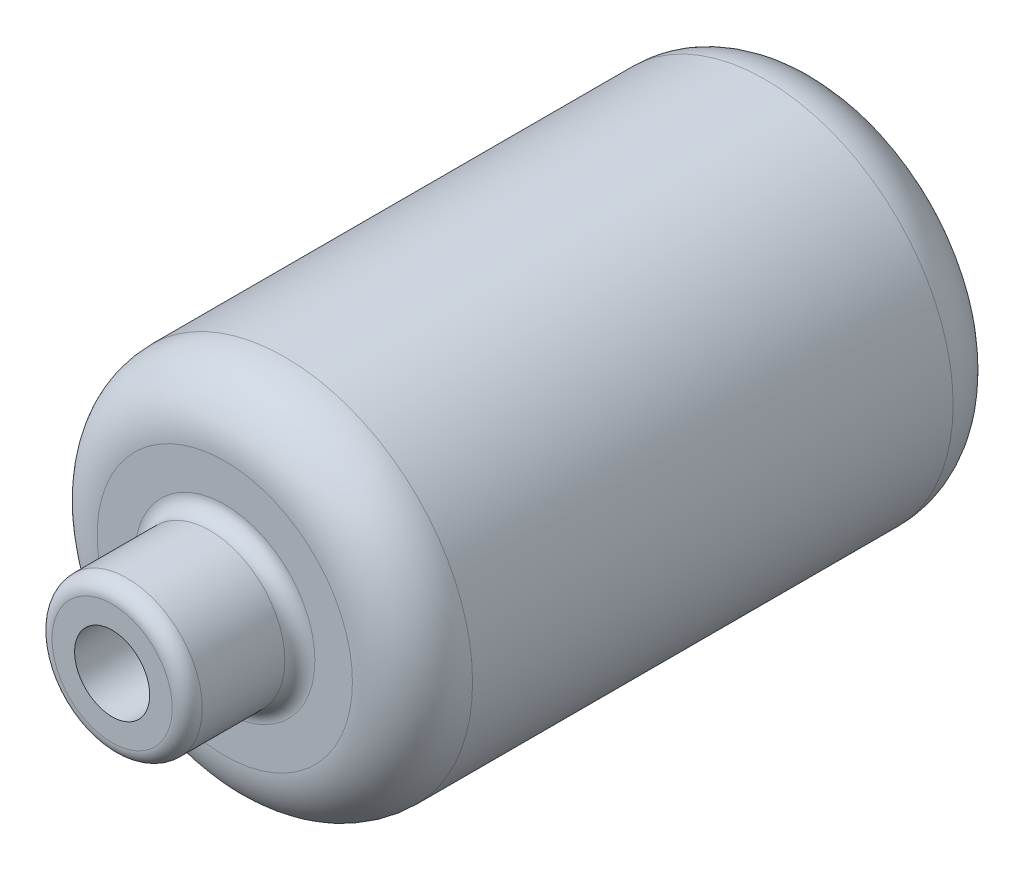
from build123d import *

# Parameters (mm, degrees)
SKETCH1_R           = 25
BOSS_EXTRUDE1_DEPTH = 80
SKETCH2_R           = 10
BOSS_EXTRUDE2_DEPTH = 15
FILLET1_R           = 8
FILLET2_R           = 8
FILLET3_R           = 2
SKETCH3_R           = 5
CUT_EXTRUDE1_DEPTH  = 26


with BuildPart() as part:
    # Sketch1 → Boss-Extrude1 (new body)
    with BuildSketch(Plane.XY):
        Circle(SKETCH1_R)
    extrude(amount=BOSS_EXTRUDE1_DEPTH)

    # Sketch2 → Boss-Extrude2 (add)
    with BuildSketch(Plane.XY.offset(80)):
        Circle(SKETCH2_R)
    extrude(amount=BOSS_EXTRUDE2_DEPTH)

    # Fillet1
    fillet1_edges = [part.edges().sort_by_distance(p)[0] for p in [
        (-25, 0, 80),
    ]]
    fillet(fillet1_edges, radius=FILLET1_R)

    # Fillet2
    fillet2_edges = [part.edges().sort_by_distance(p)[0] for p in [
        (-25, 0, 0),
    ]]
    fillet(fillet2_edges, radius=FILLET2_R)

    # Fillet3
    fillet3_edges = [part.edges().sort_by_distance(p)[0] for p in [
        (-10, 0, 80),
        (-10, 0, 95),
    ]]
    fillet(fillet3_edges, radius=FILLET3_R)

    # Sketch3 → Cut-Extrude1 (cut)
    with BuildSketch(Plane.XY.offset(95)):
        Circle(SKETCH3_R)
    extrude(amount=-CUT_EXTRUDE1_DEPTH, mode=Mode.SUBTRACT)


solid = part.part
